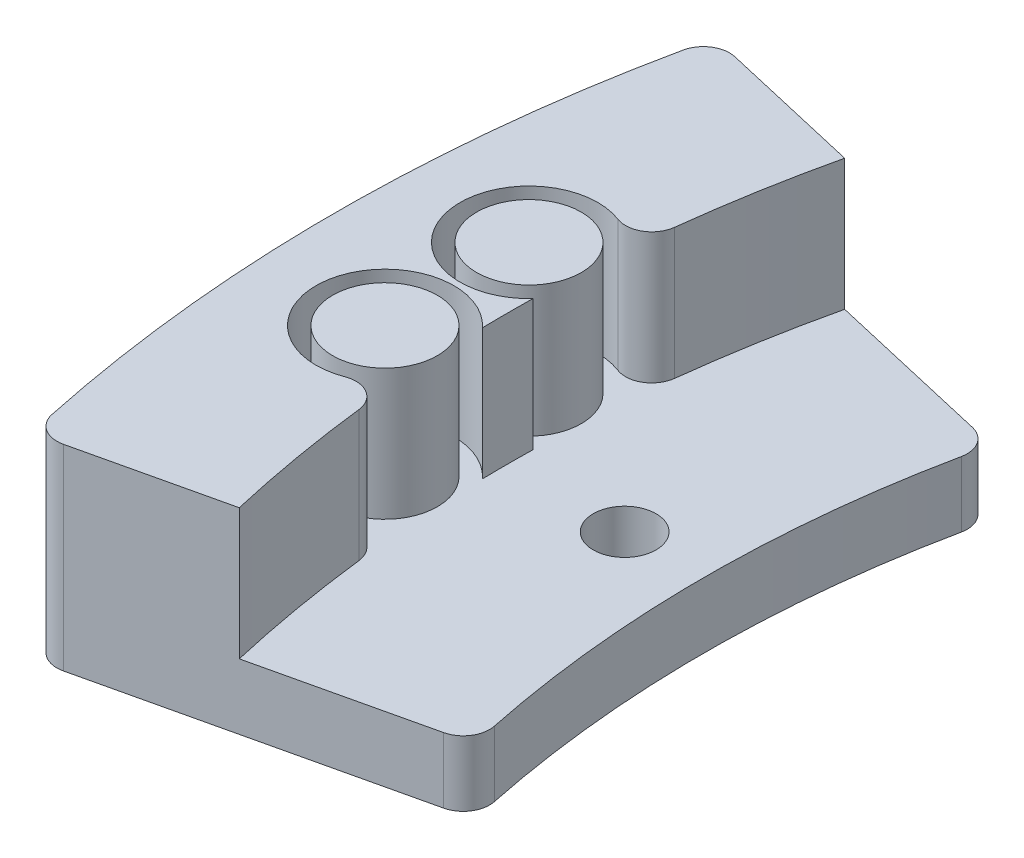
from build123d import *

# Parameters (mm, degrees)
SKETCH2_R           = 2.4
BOSS_EXTRUDE1_DEPTH = 5
BOSS_EXTRUDE2_DEPTH = 10
SKETCH4_R           = 5.27
SKETCH4_R_2         = 4
CUT_EXTRUDE1_DEPTH  = 10
CUT_EXTRUDE2_DEPTH  = 6
FILLET1_R           = 2


with BuildPart() as part:
    # Sketch2 → Boss-Extrude1 (new body)
    with BuildSketch(Plane(origin=(0, 0, 0), x_dir=(1, 0, 0), z_dir=(0, 1, 0))):
        with BuildLine():
            Line((100.252220984, 12.5), (-12.802476078, 38.600733409))
            ThreePointArc((-12.802476078, 38.600733409), (-15.776279016, 12.5), (-12.802476078, -13.600733409))
            Line((-12.802476078, -13.600733409), (100.252220984, 12.5))
        make_face()
        with Locations((6.397320984, 12.5)):
            Circle(SKETCH2_R, mode=Mode.SUBTRACT)
    extrude(amount=BOSS_EXTRUDE1_DEPTH)

    # Sketch3 → Boss-Extrude2 (add)
    with BuildSketch(Plane(origin=(0, 5, 0), x_dir=(1, 0, 0), z_dir=(0, 1, 0))):
        with BuildLine():
            Line((0.080644919, -10.626430568), (-12.802476078, -13.600733409))
            ThreePointArc((-12.802476078, -13.600733409), (-15.776279016, 12.5), (-12.802476078, 38.600733409))
            Line((-12.802476078, 38.600733409), (0.080644919, 35.626430568))
            ThreePointArc((0.080644919, 35.626430568), (-2.554279016, 12.5), (0.080644919, -10.626430568))
        make_face()
    extrude(amount=BOSS_EXTRUDE2_DEPTH)

    # Sketch4 → Cut-Extrude1 (cut)
    with BuildSketch(Plane(origin=(0, 15, 0), x_dir=(1, 0, 0), z_dir=(0, 1, 0))):
        with Locations((-6.412573781, 7)):
            Circle(SKETCH4_R)
        with Locations((-6.412573781, 7)):
            Circle(SKETCH4_R_2, mode=Mode.SUBTRACT)
    cut_extrude1 = extrude(amount=-CUT_EXTRUDE1_DEPTH, mode=Mode.SUBTRACT)

    # Mirror1: Cut-Extrude1 across plane
    add(cut_extrude1.mirror(Plane.XY.offset(-12.5)), mode=Mode.SUBTRACT)

    # Sketch5 → Cut-Extrude2 (cut, through all)
    with BuildSketch(Plane(origin=(0, 5, 0), x_dir=(1, 0, 0), z_dir=(0, 1, 0))):
        with BuildLine():
            Line((14.696195891, -7.252164753), (100.252220984, 12.5))
            Line((100.252220984, 12.5), (14.696195891, 32.252164753))
            ThreePointArc((14.696195891, 32.252164753), (12.445720984, 12.5), (14.696195891, -7.252164753))
        make_face()
    extrude(amount=-CUT_EXTRUDE2_DEPTH, mode=Mode.SUBTRACT)

    # Fillet1
    fillet1_edges = [part.edges().sort_by_distance(p)[0] for p in [
        (-2.189516169, 10, -3.847432094),
        (-2.189516169, 10, -21.152567906),
        (-12.802476078, 7.5, 13.600733409),
        (14.696195891, 2.5, -32.252164753),
        (-12.802476078, 7.5, -38.600733409),
        (14.696195891, 2.5, 7.252164753),
    ]]
    fillet(fillet1_edges, radius=FILLET1_R)


solid = part.part
